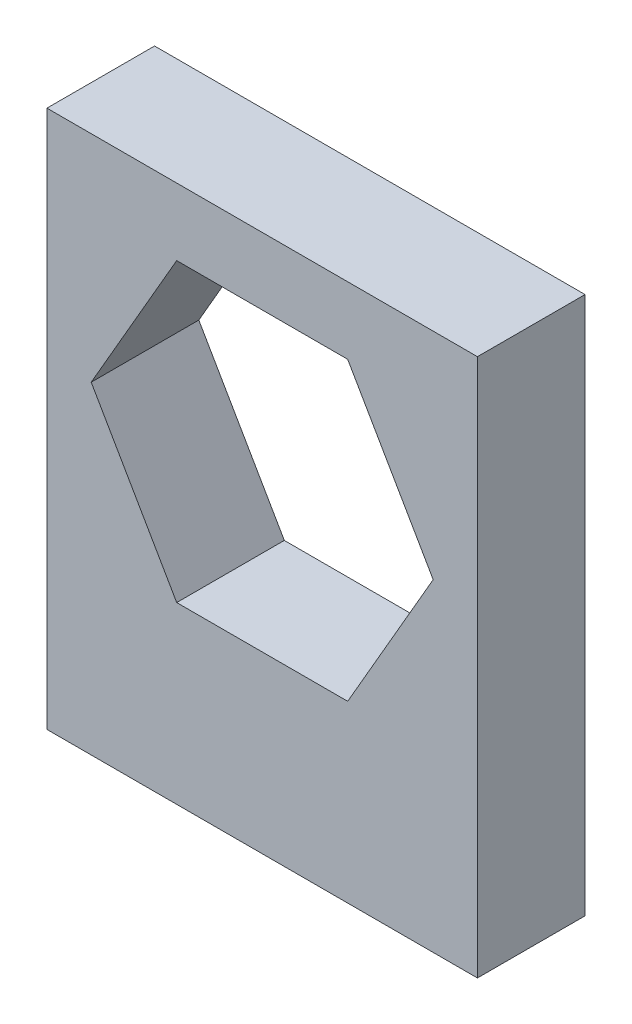
from build123d import *

# Parameters (mm, degrees)
SKETCH1_W           = 12.7
SKETCH1_H           = 15.875
BOSS_EXTRUDE1_DEPTH = 1.5875


with BuildPart() as part:
    # Sketch1 → Boss-Extrude1 (new body, symmetric)
    with BuildSketch(Plane.XY):
        with Locations((0, -1.5875)):
            Rectangle(SKETCH1_W, SKETCH1_H)
        Polygon((2.522327856, 4.3688), (-2.522327856, 4.3688), (-5.044655712, 0), (-2.522327856, -4.3688), (2.522327856, -4.3688), (5.044655712, 0), align=None, mode=Mode.SUBTRACT)
    extrude(amount=BOSS_EXTRUDE1_DEPTH, both=True)


solid = part.part
